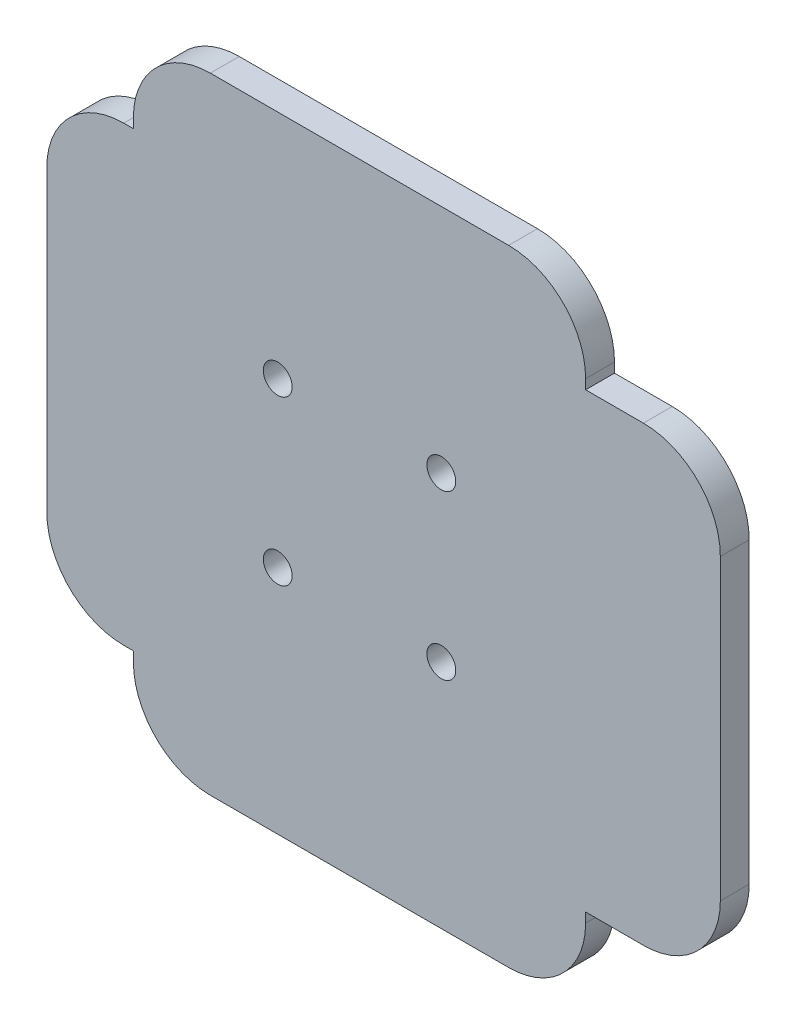
from build123d import *

# Parameters (mm, degrees)
RESSALTO_EXTRUS_O1_DEPTH = 3
ESBO_O5_R                = 1.5
CORTE_EXTRUS_O1_DEPTH    = 4


with BuildPart() as part:
    # Esboço1 → Ressalto-extrusão1 (new body)
    with BuildSketch(Plane.XY):
        with BuildLine():
            Line((7.5, -9.5), (38.5, -9.5))
            ThreePointArc((38.5, -9.5), (44.156854249, -7.156854249), (46.5, -1.5))
            Line((46.5, -1.5), (46.5, -0.5))
            Line((46.5, -0.5), (52.5, -0.5))
            ThreePointArc((52.5, -0.5), (58.156854249, 1.843145751), (60.5, 7.5))
            Line((60.5, 7.5), (60.5, 38.5))
            ThreePointArc((60.5, 38.5), (58.156854249, 44.156854249), (52.5, 46.5))
            Line((52.5, 46.5), (46.5, 46.5))
            Line((46.5, 46.5), (46.5, 47.5))
            ThreePointArc((46.5, 47.5), (44.156854249, 53.156854249), (38.5, 55.5))
            Line((38.5, 55.5), (7.5, 55.5))
            ThreePointArc((7.5, 55.5), (1.843145751, 53.156854249), (-0.5, 47.5))
            Line((-0.5, 47.5), (-0.5, 46.5))
            Line((-0.5, 46.5), (-1.5, 46.5))
            ThreePointArc((-1.5, 46.5), (-7.156854249, 44.156854249), (-9.5, 38.5))
            Line((-9.5, 38.5), (-9.5, 7.5))
            ThreePointArc((-9.5, 7.5), (-7.156854249, 1.843145751), (-1.5, -0.5))
            Line((-1.5, -0.5), (-0.5, -0.5))
            Line((-0.5, -0.5), (-0.5, -1.5))
            ThreePointArc((-0.5, -1.5), (1.843145751, -7.156854249), (7.5, -9.5))
        make_face()
    extrude(amount=RESSALTO_EXTRUS_O1_DEPTH)

    # Esboço5 → Corte-extrusão1 (cut, through all)
    with BuildSketch(Plane.XY.offset(3)):
        with Locations((31.5, 31.5)):
            Circle(ESBO_O5_R)
        with Locations((14.5, 31.5)):
            Circle(ESBO_O5_R)
        with Locations((14.5, 14.5)):
            Circle(ESBO_O5_R)
        with Locations((31.5, 14.5)):
            Circle(ESBO_O5_R)
    extrude(amount=-CORTE_EXTRUS_O1_DEPTH, mode=Mode.SUBTRACT)


solid = part.part
